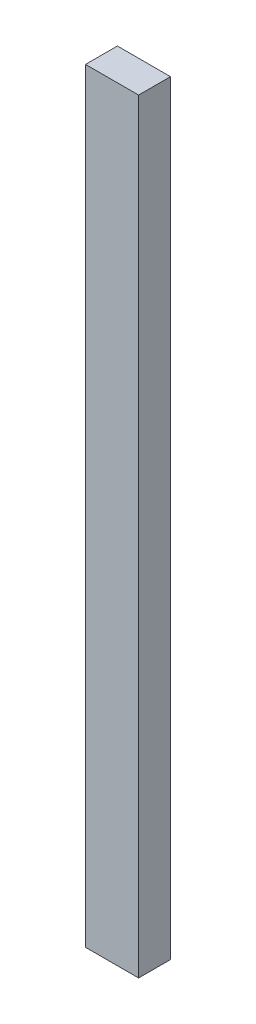
from build123d import *

# Parameters (mm, degrees)
SKETCH1_W           = 63.5
SKETCH1_H           = 38.1
BOSS_EXTRUDE1_DEPTH = 914.4


with BuildPart() as part:
    # Sketch1 → Boss-Extrude1 (new body)
    with BuildSketch(Plane(origin=(0, 0, 0), x_dir=(1, 0, 0), z_dir=(0, 1, 0))):
        Rectangle(SKETCH1_W, SKETCH1_H)
    extrude(amount=BOSS_EXTRUDE1_DEPTH)


solid = part.part
